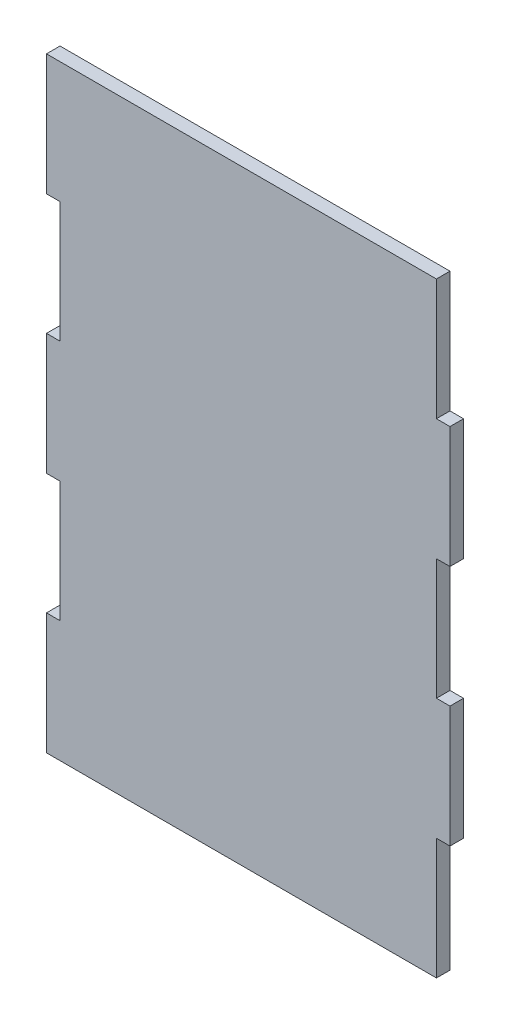
from build123d import *

# Parameters (mm, degrees)
SKETCH1_W           = 150.025
SKETCH1_H           = 241.325
SKETCH1_W_2         = 5.4
SKETCH1_H_2         = 48.265
BOSS_EXTRUDE1_DEPTH = 5.4
BOSS_EXTRUDE2_DEPTH = 5.4


with BuildPart() as part:
    # Sketch1 → Boss-Extrude1 (new body)
    with BuildSketch(Plane.XY):
        Rectangle(SKETCH1_W, SKETCH1_H)
        Polygon((-75.0125, -72.3975), (-75.0125, -120.6625), (75.0125, -120.6625), (75.0125, -72.3975), (75.0125, -24.1325), (75.0125, 24.1325), (75.0125, 72.3975), (75.0125, 120.6625), (55.5875, 120.6625), (-75.0125, 120.6625), (-75.0125, 72.3975), (-75.0125, 24.1325), (-75.0125, -24.1325), align=None)
        Polygon((-75.0125, -72.3975), (-75.0125, -120.6625), (75.0125, -120.6625), (75.0125, -72.3975), (75.0125, -24.1325), (75.0125, 24.1325), (75.0125, 72.3975), (75.0125, 120.6625), (55.5875, 120.6625), (-75.0125, 120.6625), (-75.0125, 72.3975), (-75.0125, 24.1325), (-75.0125, -24.1325), align=None)
        Polygon((-75.0125, -72.3975), (-75.0125, -120.6625), (75.0125, -120.6625), (75.0125, -72.3975), (75.0125, -24.1325), (75.0125, 24.1325), (75.0125, 72.3975), (75.0125, 120.6625), (55.5875, 120.6625), (-75.0125, 120.6625), (-75.0125, 72.3975), (-75.0125, 24.1325), (-75.0125, -24.1325), align=None)
        with Locations((-77.7125, 96.53)):
            Rectangle(SKETCH1_W_2, SKETCH1_H_2)
        Polygon((-75.0125, -72.3975), (-75.0125, -120.6625), (75.0125, -120.6625), (75.0125, -72.3975), (75.0125, -24.1325), (75.0125, 24.1325), (75.0125, 72.3975), (75.0125, 120.6625), (55.5875, 120.6625), (-75.0125, 120.6625), (-75.0125, 72.3975), (-75.0125, 24.1325), (-75.0125, -24.1325), align=None)
        with Locations((77.7125, 48.265)):
            Rectangle(SKETCH1_W_2, SKETCH1_H_2)
        with Locations((-77.7125, 0)):
            Rectangle(SKETCH1_W_2, SKETCH1_H_2)
        with Locations((77.7125, -48.265)):
            Rectangle(SKETCH1_W_2, SKETCH1_H_2)
        with Locations((-77.7125, -96.53)):
            Rectangle(SKETCH1_W_2, SKETCH1_H_2)
    extrude(amount=BOSS_EXTRUDE1_DEPTH)

    # Sketch2 → Boss-Extrude2 (add)
    with BuildSketch(Plane.XY.offset(5.4)):
        Polygon((-80.45314, -120.70314), (75.05314, -120.70314), (75.05314, -72.43814), (80.45314, -72.43814), (80.45314, -24.09186), (75.05314, -24.09186), (75.05314, 24.09186), (80.45314, 24.09186), (80.45314, 72.43814), (75.05314, 72.43814), (75.05314, 120.70314), (-80.45314, 120.70314), (-80.45314, 72.35686), (-75.05314, 72.35686), (-75.05314, 24.17314), (-80.45314, 24.17314), (-80.45314, -24.17314), (-75.05314, -24.17314), (-75.05314, -72.35686), (-80.45314, -72.35686), align=None)
    extrude(amount=-BOSS_EXTRUDE2_DEPTH)


solid = part.part
